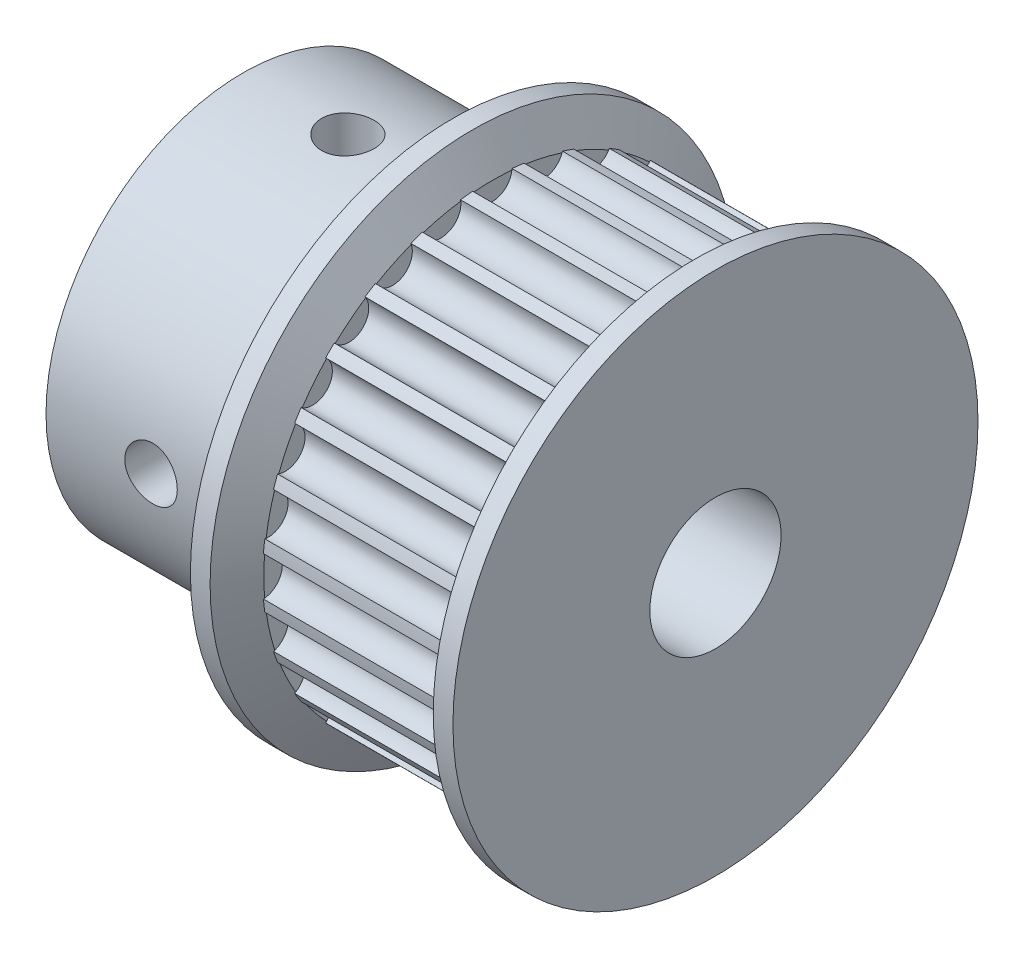
from build123d import *

# Parameters (mm, degrees)
SCHIZZO5_R               = 0.75
TAGLIO_ESTRUSIONE1_DEPTH = 7
SCHIZZO6_R               = 1
TAGLIO_ESTRUSIONE2_DEPTH = 10
SCHIZZO7_R               = 1
TAGLIO_ESTRUSIONE3_DEPTH = 10


with BuildPart() as part:
    # Schizzo4 → Rivoluzione1 (revolve)
    with BuildSketch(Plane.XY):
        Polygon((0, 2.5), (0, 7.5), (8, 7.5), (8, 10), (8.75, 10), (9.5, 8.700961894), (9.5, 8.75), (16.5, 8.75), (16.5, 8.700961894), (17.25, 10), (18, 10), (18, 2.5), align=None)
    revolve(axis=Axis((0, 0, 0), (1, 0, 0)))

    # Schizzo5 → Taglio-Estrusione1 (cut)
    with BuildSketch(Plane.ZY.offset(-9.5)):
        with Locations((0, 8.75)):
            Circle(SCHIZZO5_R)
        with Locations((1.947058172, 8.530619232)):
            Circle(SCHIZZO5_R)
        with Locations((3.796482717, 7.883477594)):
            Circle(SCHIZZO5_R)
        with Locations((5.455535766, 6.841025472)):
            Circle(SCHIZZO5_R)
        with Locations((6.841025472, 5.455535766)):
            Circle(SCHIZZO5_R)
        with Locations((7.883477594, 3.796482717)):
            Circle(SCHIZZO5_R)
        with Locations((8.530619232, 1.947058172)):
            Circle(SCHIZZO5_R)
        with Locations((8.75, 0)):
            Circle(SCHIZZO5_R)
        with Locations((8.530619232, -1.947058172)):
            Circle(SCHIZZO5_R)
        with Locations((7.883477594, -3.796482717)):
            Circle(SCHIZZO5_R)
        with Locations((6.841025472, -5.455535766)):
            Circle(SCHIZZO5_R)
        with Locations((5.455535766, -6.841025472)):
            Circle(SCHIZZO5_R)
        with Locations((3.796482717, -7.883477594)):
            Circle(SCHIZZO5_R)
        with Locations((1.947058172, -8.530619232)):
            Circle(SCHIZZO5_R)
        with Locations((0, -8.75)):
            Circle(SCHIZZO5_R)
        with Locations((-1.947058172, -8.530619232)):
            Circle(SCHIZZO5_R)
        with Locations((-3.796482717, -7.883477594)):
            Circle(SCHIZZO5_R)
        with Locations((-5.455535766, -6.841025472)):
            Circle(SCHIZZO5_R)
        with Locations((-6.841025472, -5.455535766)):
            Circle(SCHIZZO5_R)
        with Locations((-7.883477594, -3.796482717)):
            Circle(SCHIZZO5_R)
        with Locations((-8.530619232, -1.947058172)):
            Circle(SCHIZZO5_R)
        with Locations((-8.75, 0)):
            Circle(SCHIZZO5_R)
        with Locations((-8.530619232, 1.947058172)):
            Circle(SCHIZZO5_R)
        with Locations((-7.883477594, 3.796482717)):
            Circle(SCHIZZO5_R)
        with Locations((-6.841025472, 5.455535766)):
            Circle(SCHIZZO5_R)
        with Locations((-5.455535766, 6.841025472)):
            Circle(SCHIZZO5_R)
        with Locations((-3.796482717, 7.883477594)):
            Circle(SCHIZZO5_R)
        with Locations((-1.947058172, 8.530619232)):
            Circle(SCHIZZO5_R)
    extrude(amount=-TAGLIO_ESTRUSIONE1_DEPTH, mode=Mode.SUBTRACT)

    # Schizzo6 → Taglio-Estrusione2 (cut)
    with BuildSketch(Plane.XY):
        with Locations((4, 0)):
            Circle(SCHIZZO6_R)
    extrude(amount=TAGLIO_ESTRUSIONE2_DEPTH, mode=Mode.SUBTRACT)

    # Schizzo7 → Taglio-Estrusione3 (cut)
    with BuildSketch(Plane(origin=(0, 0, 0), x_dir=(1, 0, 0), z_dir=(0, 1, 0))):
        with Locations((4, 0)):
            Circle(SCHIZZO7_R)
    extrude(amount=TAGLIO_ESTRUSIONE3_DEPTH, mode=Mode.SUBTRACT)


solid = part.part
